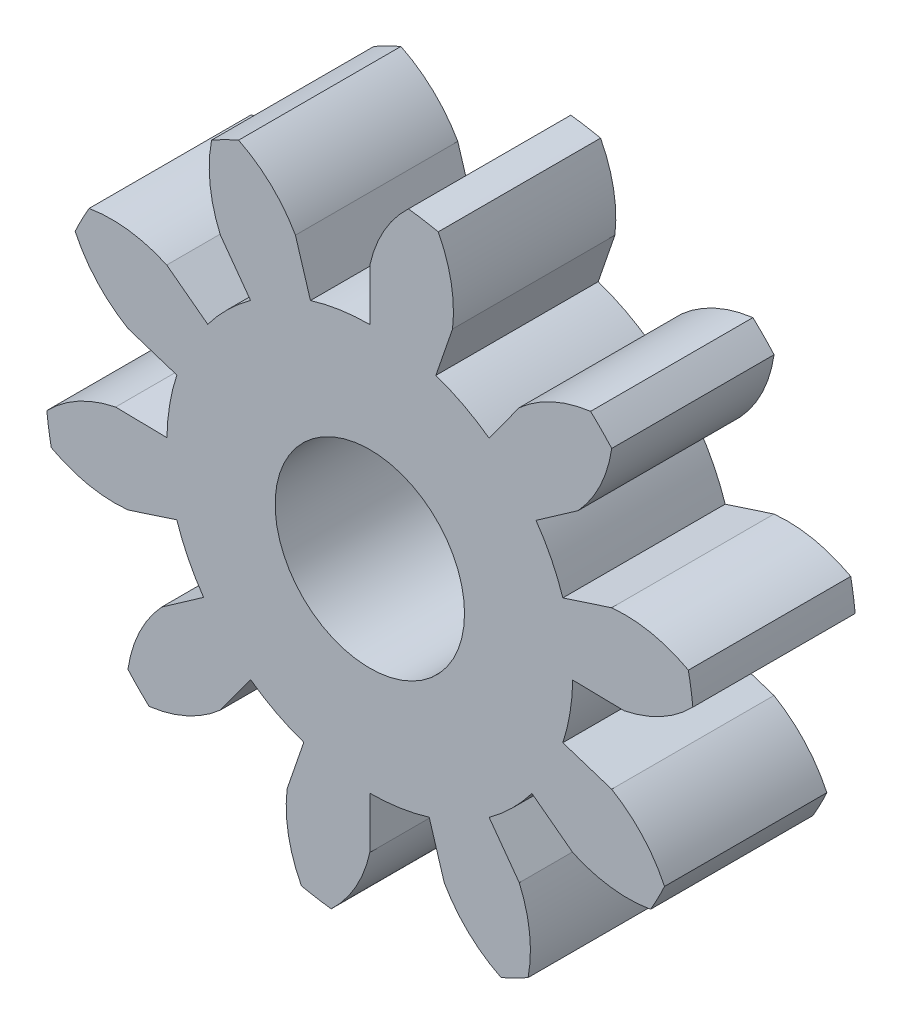
from build123d import *

# Parameters (mm, degrees)
BOSS_EXTRU_1_DEPTH           = 3
R_P_TITION_CIRCULAIRE2_COUNT = 10
ESQUISSE5_R                  = 3.75
BOSS_EXTRU_2_DEPTH           = 3
ESQUISSE6_R                  = 1.75
ENL_V_MAT_EXTRU_1_DEPTH      = 4


with BuildPart() as part:
    # Esquisse4 → Boss.-Extru.1 (new body)
    with BuildSketch(Plane.XY):
        with BuildLine():
            Line((0, 4.698463104), (0, 3.75))
            ThreePointArc((0, 3.75), (0.618511546, 3.69864076), (1.220081074, 3.54596985))
            Line((1.220081074, 3.54596985), (1.528668242, 4.442828935))
            ThreePointArc((1.528668242, 4.442828935), (1.503976571, 5.174164178), (1.263823322, 5.865385802))
            ThreePointArc((1.263823322, 5.865385802), (0.989618473, 5.917825215), (0.71327115, 5.957452834))
            ThreePointArc((0.71327115, 5.957452834), (0.261291789, 5.381974273), (0, 4.698463104))
        make_face()
    extrude(amount=BOSS_EXTRU_1_DEPTH)


with BuildPart() as r_p_tition_circulaire2_1:
    # Répétition circulaire2: pattern copy
    add(part.part.rotate(Axis((0, 0, 0), (0, 0, 1)), 1 * 360 / R_P_TITION_CIRCULAIRE2_COUNT))


with BuildPart() as r_p_tition_circulaire2_2:
    # Répétition circulaire2: pattern copy
    add(part.part.rotate(Axis((0, 0, 0), (0, 0, 1)), 2 * 360 / R_P_TITION_CIRCULAIRE2_COUNT))


with BuildPart() as r_p_tition_circulaire2_3:
    # Répétition circulaire2: pattern copy
    add(part.part.rotate(Axis((0, 0, 0), (0, 0, 1)), 3 * 360 / R_P_TITION_CIRCULAIRE2_COUNT))


with BuildPart() as r_p_tition_circulaire2_4:
    # Répétition circulaire2: pattern copy
    add(part.part.rotate(Axis((0, 0, 0), (0, 0, 1)), 4 * 360 / R_P_TITION_CIRCULAIRE2_COUNT))


with BuildPart() as r_p_tition_circulaire2_5:
    # Répétition circulaire2: pattern copy
    add(part.part.rotate(Axis((0, 0, 0), (0, 0, 1)), 5 * 360 / R_P_TITION_CIRCULAIRE2_COUNT))


with BuildPart() as r_p_tition_circulaire2_6:
    # Répétition circulaire2: pattern copy
    add(part.part.rotate(Axis((0, 0, 0), (0, 0, 1)), 6 * 360 / R_P_TITION_CIRCULAIRE2_COUNT))


with BuildPart() as r_p_tition_circulaire2_7:
    # Répétition circulaire2: pattern copy
    add(part.part.rotate(Axis((0, 0, 0), (0, 0, 1)), 7 * 360 / R_P_TITION_CIRCULAIRE2_COUNT))


with BuildPart() as r_p_tition_circulaire2_8:
    # Répétition circulaire2: pattern copy
    add(part.part.rotate(Axis((0, 0, 0), (0, 0, 1)), 8 * 360 / R_P_TITION_CIRCULAIRE2_COUNT))


with BuildPart() as r_p_tition_circulaire2_9:
    # Répétition circulaire2: pattern copy
    add(part.part.rotate(Axis((0, 0, 0), (0, 0, 1)), 9 * 360 / R_P_TITION_CIRCULAIRE2_COUNT))


with BuildPart() as part_1:
    add(part.part)

    add(r_p_tition_circulaire2_1.part)  # Boss.-Extru.2 merges Répétition circulaire2_1

    add(r_p_tition_circulaire2_2.part)  # Boss.-Extru.2 merges Répétition circulaire2_2

    add(r_p_tition_circulaire2_3.part)  # Boss.-Extru.2 merges Répétition circulaire2_3

    add(r_p_tition_circulaire2_4.part)  # Boss.-Extru.2 merges Répétition circulaire2_4

    add(r_p_tition_circulaire2_5.part)  # Boss.-Extru.2 merges Répétition circulaire2_5

    add(r_p_tition_circulaire2_6.part)  # Boss.-Extru.2 merges Répétition circulaire2_6

    add(r_p_tition_circulaire2_7.part)  # Boss.-Extru.2 merges Répétition circulaire2_7

    add(r_p_tition_circulaire2_8.part)  # Boss.-Extru.2 merges Répétition circulaire2_8

    add(r_p_tition_circulaire2_9.part)  # Boss.-Extru.2 merges Répétition circulaire2_9
    # Esquisse5 → Boss.-Extru.2 (add)
    with BuildSketch(Plane.XY):
        Circle(ESQUISSE5_R)
    extrude(amount=BOSS_EXTRU_2_DEPTH)

    # Esquisse6 → Enlèv. mat.-Extru.1 (cut, through all)
    with BuildSketch(Plane.XY.offset(3)):
        Circle(ESQUISSE6_R)
    extrude(amount=-ENL_V_MAT_EXTRU_1_DEPTH, mode=Mode.SUBTRACT)


solid = part_1.part
